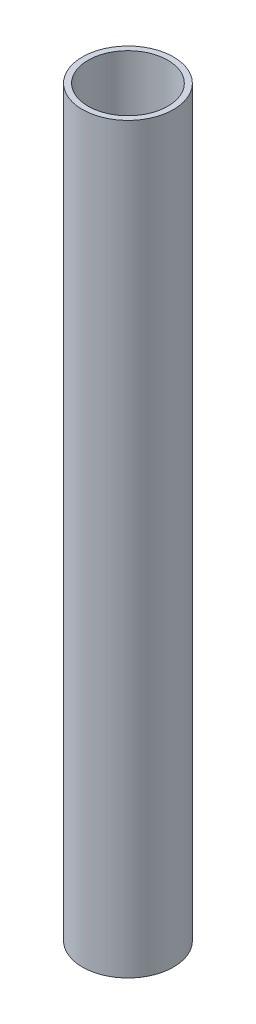
from build123d import *

# Parameters (mm, degrees)
SKETCH_1_R      = 4
SKETCH_1_R_2    = 3.5
EXTRUDE_1_DEPTH = 65.19


with BuildPart() as part:
    # 草图1 → 凸台-拉伸1 (new body)
    with BuildSketch(Plane(origin=(0, 0, 0), x_dir=(1, 0, 0), z_dir=(0, 1, 0))):
        Circle(SKETCH_1_R)
        Circle(SKETCH_1_R_2, mode=Mode.SUBTRACT)
    extrude(amount=EXTRUDE_1_DEPTH)


solid = part.part
